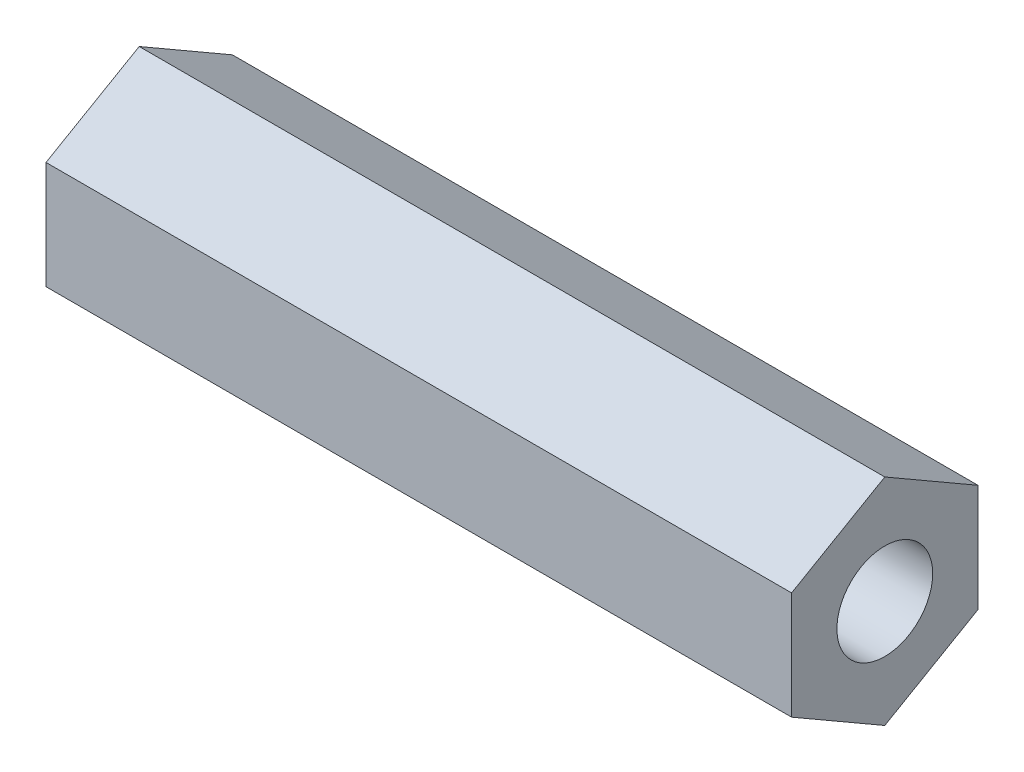
from build123d import *

# Parameters (mm, degrees)
SKETCH1_R           = 3.2639
BOSS_EXTRUDE1_DEPTH = 50.8


with BuildPart() as part:
    # Sketch1 → Boss-Extrude1 (new body)
    with BuildSketch(Plane(origin=(0, 0, 0), x_dir=(0, 0, -1), z_dir=(1, 0, 0))):
        Polygon((0, 7.332348419), (-6.35, 3.666174209), (-6.35, -3.666174209), (0, -7.332348419), (6.35, -3.666174209), (6.35, 3.666174209), align=None)
        Circle(SKETCH1_R, mode=Mode.SUBTRACT)
    extrude(amount=BOSS_EXTRUDE1_DEPTH)


solid = part.part
